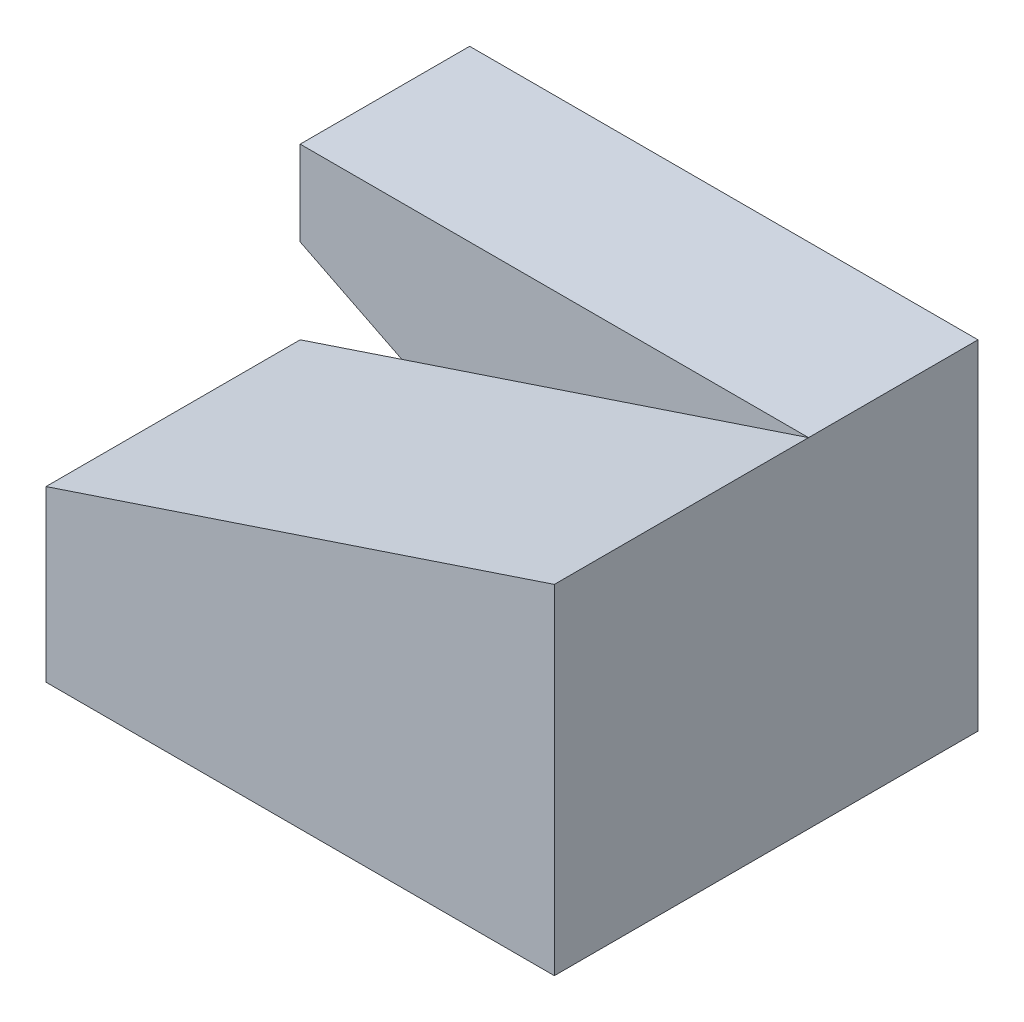
from build123d import *

# Parameters (mm, degrees)
BOSS_EXTRUDE1_DEPTH = 15
BOSS_EXTRUDE2_DEPTH = 10


with BuildPart() as part:
    # Sketch1 → Boss-Extrude1 (new body)
    with BuildSketch(Plane.XY):
        Polygon((-36.752136752, 6.282051282), (-36.752136752, -3.717948718), (-6.752136752, -3.717948718), (-6.752136752, 16.282051282), align=None)
    extrude(amount=BOSS_EXTRUDE1_DEPTH)

    # Sketch2 → Boss-Extrude2 (add)
    with BuildSketch(Plane(origin=(0, 0, 0), x_dir=(-1, 0, 0), z_dir=(0, 0, -1))):
        Polygon((6.752136752, -3.717948718), (6.752136752, 16.282051282), (36.752136752, 16.282051282), (36.752136752, 11.282051282), align=None)
    extrude(amount=BOSS_EXTRUDE2_DEPTH)


solid = part.part
